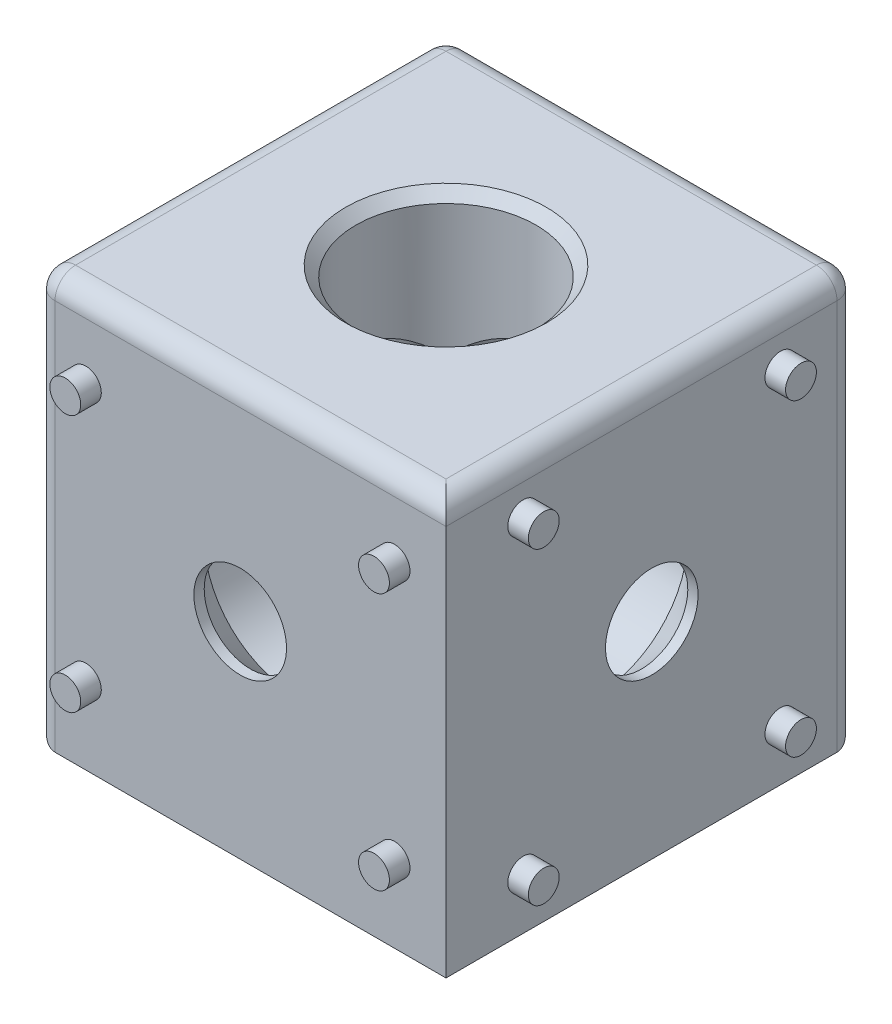
from build123d import *

# Parameters (mm, degrees)
SKETCH_1_W      = 40
SKETCH_1_H      = 40
EXTRUDE_1_DEPTH = 20
SKETCH_5_R      = 1.5
EXTRUDE_2_DEPTH = 2
FILLET_1_R      = 2


with BuildPart() as part:
    # Эскиз1 → Бобышка-Вытянуть1 (new body, symmetric)
    with BuildSketch(Plane(origin=(0, 0, 0), x_dir=(1, 0, 0), z_dir=(0, 1, 0))):
        Rectangle(SKETCH_1_W, SKETCH_1_H)
    extrude(amount=EXTRUDE_1_DEPTH, both=True)

    # Эскиз4 → Вырез-Повернуть1 (revolve, cut)
    with BuildSketch(Plane.XY):
        Polygon((-4.5, -20), (-4.5, -19), (-8.75, -14.75), (-8.75, 19), (-9.75, 20), (0, 20), (0, -20), align=None)
    cut_revolve_1 = revolve(axis=Axis((0, 20, 0), (0, -1, 0)), mode=Mode.SUBTRACT)

    # Эскиз5 → Бобышка-Вытянуть2 (add)
    with BuildSketch(Plane.XZ.offset(20)):
        with Locations(Location((-15, 12.5, 0), (0, 0, 270))):  # turned: the seam where the file's is
            Circle(SKETCH_5_R)
        with Locations(Location((-15, -12.5, 0), (0, 0, 270))):  # turned: the seam where the file's is
            Circle(SKETCH_5_R)
        with Locations(Location((15, -12.5, 0), (0, 0, 270))):  # turned: the seam where the file's is
            Circle(SKETCH_5_R)
        with Locations(Location((15, 12.5, 0), (0, 0, 270))):  # turned: the seam where the file's is
            Circle(SKETCH_5_R)
    extrude_2 = extrude(amount=EXTRUDE_2_DEPTH)

    # Зеркальное отражение1: Вырез-Повернуть1, Бобышка-Вытянуть2 across plane
    add(cut_revolve_1.mirror(Plane(origin=(0, 0, 0), x_dir=(0, 0, 1), z_dir=(0.707106781, 0.707106781, 0))), mode=Mode.SUBTRACT)
    add(extrude_2.mirror(Plane(origin=(0, 0, 0), x_dir=(0, 0, 1), z_dir=(0.707106781, 0.707106781, 0))))

    # Скругление1
    fillet_1_edges = [part.edges().sort_by_distance(p)[0] for p in [
        (-20, 20, 0),
        (0, 20, 20),
        (20, 20, 0),
        (-20, -20, 0),
        (0, -20, -20),
        (-20, 0, 20),
        (-20, 0, -20),
        (20, 0, -20),
        (0, 20, -20),
    ]]
    fillet(fillet_1_edges, radius=FILLET_1_R)

    # Зеркальное отражение2: Вырез-Повернуть1, Бобышка-Вытянуть2 across plane
    add(cut_revolve_1.mirror(Plane(origin=(0, 0, 0), x_dir=(0, -0.707106781, 0.707106781), z_dir=(0, 0.707106781, 0.707106781))), mode=Mode.SUBTRACT)
    add(extrude_2.mirror(Plane(origin=(0, 0, 0), x_dir=(0, -0.707106781, 0.707106781), z_dir=(0, 0.707106781, 0.707106781))))


solid = part.part
